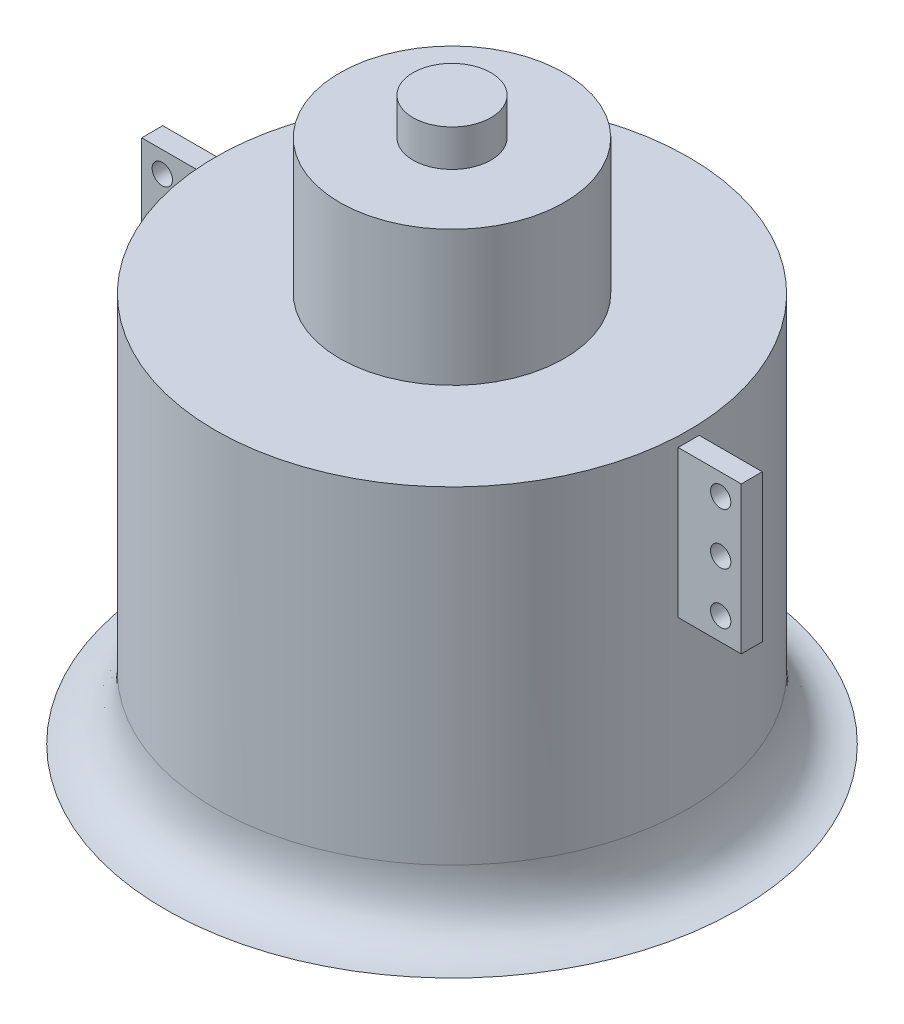
from build123d import *

# Parameters (mm, degrees)
SKETCH_1_R        = 45
EXTRUDE_1_DEPTH   = 29.82
SKETCH_2_W        = 12
SKETCH_2_H        = 28
SKETCH_2_R        = 1.93
EXTRUDE_2_DEPTH   = 2
EXTRUDE_2_2_DEPTH = 2
SKETCH_3_R        = 21.35
EXTRUDE_3_DEPTH   = 25.7
SKETCH_4_R        = 7.41
EXTRUDE_4_DEPTH   = 7
SKETCH_5_R        = 45
EXTRUDE_5_DEPTH   = 32.46


with BuildPart() as part:
    # 草图1 → 凸台-拉伸1 (new body)
    with BuildSketch(Plane(origin=(0, 0, 0), x_dir=(1, 0, 0), z_dir=(0, 1, 0))):
        Circle(SKETCH_1_R)
    extrude(amount=EXTRUDE_1_DEPTH)

    # 草图3 → 凸台-拉伸3 (add)
    with BuildSketch(Plane(origin=(0, 29.82, 0), x_dir=(1, 0, 0), z_dir=(0, 1, 0))):
        Circle(SKETCH_3_R)
    extrude(amount=EXTRUDE_3_DEPTH)

    # 草图4 → 凸台-拉伸4 (add)
    with BuildSketch(Plane(origin=(0, 55.52, 0), x_dir=(1, 0, 0), z_dir=(0, 1, 0))):
        Circle(SKETCH_4_R)
    extrude(amount=EXTRUDE_4_DEPTH)

    # 草图5 → 凸台-拉伸5 (add)
    with BuildSketch(Plane.XZ):
        Circle(SKETCH_5_R)
    extrude(amount=EXTRUDE_5_DEPTH)

    # 草图6 → 旋转1 (revolve)
    with BuildSketch(Plane.XY):
        with BuildLine():
            Line((-54.5, -44.34), (0, -44.34))
            Line((0, -44.34), (0, -32.46))
            Line((0, -32.46), (-45, -32.46))
            add(Edge.make_bspline(
                [(-45, -32.46), (-45, -44.34), (-54.5, -44.34)],
                knots=[0, 0, 0, 1, 1, 1], degree=2))
        make_face()
    revolve(axis=Axis((0, -44.34, 0), (0, 1, 0)))


with BuildPart() as body_2:
    # 草图2 → 凸台-拉伸2 (new body, symmetric)
    with BuildSketch(Plane.XY):
        with Locations((51, 14)):
            Rectangle(SKETCH_2_W, SKETCH_2_H)
        with Locations((53.09, 23.97)):
            Circle(SKETCH_2_R, mode=Mode.SUBTRACT)
        with Locations((53.09, 14.145)):
            Circle(SKETCH_2_R, mode=Mode.SUBTRACT)
        with Locations((53.09, 4.33)):
            Circle(SKETCH_2_R, mode=Mode.SUBTRACT)
    extrude(amount=EXTRUDE_2_DEPTH, both=True)


with BuildPart() as body_3:
    # 草图2 → Extrude 2 2 (new body, symmetric)
    with BuildSketch(Plane.XY):
        with Locations((-51, 14)):
            Rectangle(SKETCH_2_W, SKETCH_2_H)
        with Locations((-53.09, 4.33)):
            Circle(SKETCH_2_R, mode=Mode.SUBTRACT)
        with Locations((-53.09, 14.145)):
            Circle(SKETCH_2_R, mode=Mode.SUBTRACT)
        with Locations((-53.09, 23.97)):
            Circle(SKETCH_2_R, mode=Mode.SUBTRACT)
    extrude(amount=EXTRUDE_2_2_DEPTH, both=True)


solid = Compound([part.part, body_2.part, body_3.part])
